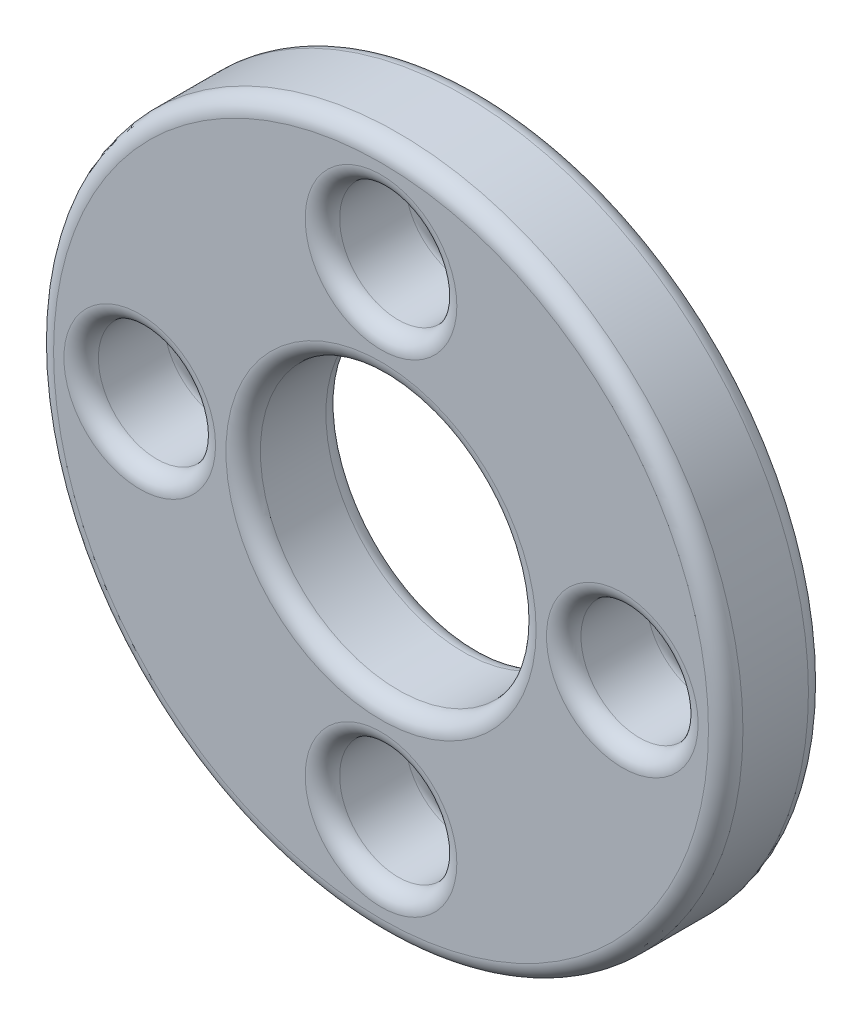
from build123d import *

# Parameters (mm, degrees)
SKETCH1_R            = 10
BOSS_EXTRUDE1_DEPTH  = 2.9
M3_CLEARANCE_HOLE1_D = 3.4
SKETCH4_R            = 4
CUT_EXTRUDE1_DEPTH   = 3.9
FILLET1_R            = 0.5


with BuildPart() as part:
    # Sketch1 → Boss-Extrude1 (new body)
    with BuildSketch(Plane.XY):
        Circle(SKETCH1_R)
    extrude(amount=BOSS_EXTRUDE1_DEPTH)

    # M3 Clearance Hole1 (through all)
    with Locations(Plane.XY.offset(2.9)):
        with Locations((7, 0), (0, 7), (-7, 0), (0, -7)):
            Hole(M3_CLEARANCE_HOLE1_D / 2)

    # Sketch4 → Cut-Extrude1 (cut, through all)
    with BuildSketch(Plane.XY.offset(2.9)):
        Circle(SKETCH4_R)
    extrude(amount=-CUT_EXTRUDE1_DEPTH, mode=Mode.SUBTRACT)

    # Fillet1
    fillet1_edges = [part.edges().sort_by_distance(p)[0] for p in [
        (1.7, -7, 2.9),
        (1.7, -7, 0),
        (-5.3, 0, 2.9),
        (-5.3, 0, 0),
        (-10, 0, 0),
        (1.7, 7, 2.9),
        (1.7, 7, 0),
        (-4, 0, 0),
        (-4, 0, 2.9),
        (-10, 0, 2.9),
        (8.7, 0, 2.9),
        (8.7, 0, 0),
    ]]
    fillet(fillet1_edges, radius=FILLET1_R)


solid = part.part
